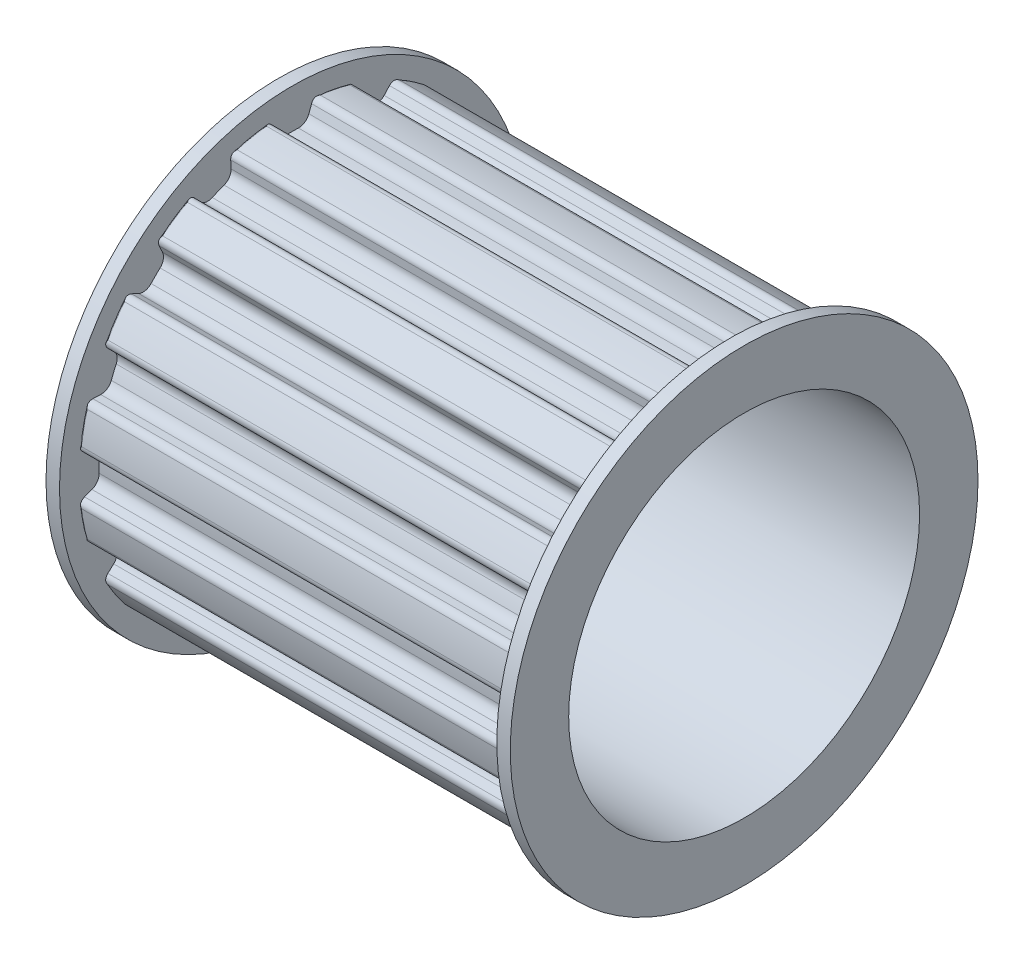
from build123d import *

# Parameters (mm, degrees)
CHAMFER_1_SIZE           = 1
FILLET_1_R               = 2
FILLET_2_R               = 2.5
CUT_EXTRUDE_3_DEPTH      = 123
PATTERN_CIRCULAR_3_COUNT = 16
EXTRUDE_START            = -123.002
SKETCH_7_R               = 25.3232
EXTRUDE_2_DEPTH          = 123.002
SKETCH_8_W               = 100
SKETCH_8_H               = 74.934258
CUT_EXTRUDE_4_DEPTH      = 40
SKETCH_9_R               = 34.654
EXTRUDE_3_DEPTH          = 2
SKETCH_10_R              = 34.454
EXTRUDE_4_DEPTH          = 2
SKETCH_11_R              = 21.5
CUT_EXTRUDE_5_DEPTH      = 10
SKETCH_12_R              = 26
CUT_EXTRUDE_6_DEPTH      = 40
SKETCH_13_R              = 2.5
CUT_EXTRUDE_7_DEPTH      = 60
SKETCH_17_R              = 11
SKETCH_17_R_2            = 2.5
CUT_EXTRUDE_9_DEPTH      = 1.5
SKETCH_15_R              = 1.5
CUT_EXTRUDE_8_DEPTH      = 30


with BuildPart() as part:
    # 草图1 → 旋转1 (revolve)
    with BuildSketch(Plane.XY):
        with BuildLine():
            Line((0, 6.3308), (0, 12.6616))
            Line((0, 12.6616), (44, 14.421131))
            Line((44, 14.421131), (44, 23.563669))
            Line((44, 23.563669), (0, 25.3232))
            Line((0, 25.3232), (0, 31.454))
            ThreePointArc((0, 31.454), (0.058579, 31.595421), (0.2, 31.654))
            Line((0.2, 31.654), (122.8, 31.654))
            ThreePointArc((122.8, 31.654), (122.941421, 31.595421), (123, 31.454))
            Line((123, 31.454), (123, 25.3232))
            Line((123, 25.3232), (79, 23.563669))
            Line((79, 23.563669), (79, 14.421131))
            Line((79, 14.421131), (123, 12.6616))
            Line((123, 12.6616), (123, 6.3308))
            Line((123, 6.3308), (0, 6.3308))
        make_face()
    revolve(axis=Axis((0, 0, 0), (1, 0, 0)))

    # 倒角1
    chamfer_1_edges = [part.edges().sort_by_distance(p)[0] for p in [
        (0, -6.3308, 0),
        (123, -6.3308, 0),
    ]]
    chamfer(chamfer_1_edges, length=CHAMFER_1_SIZE)

    # 圆角1
    fillet_1_edges = [part.edges().sort_by_distance(p)[0] for p in [
        (79, -14.421131, 0),
        (79, -23.563669, 0),
        (44, -23.563669, 0),
        (44, -14.421131, 0),
    ]]
    fillet(fillet_1_edges, radius=FILLET_1_R)

    # 圆角2
    fillet_2_edges = [part.edges().sort_by_distance(p)[0] for p in [
        (0, -12.6616, 0),
        (123, -12.6616, 0),
    ]]
    fillet(fillet_2_edges, radius=FILLET_2_R)

    # 草图6 → 切除-拉伸3 (cut)
    with BuildSketch(Plane(origin=(0, 0, 0), x_dir=(0, 0, -1), z_dir=(1, 0, 0))):
        with BuildLine():
            Line((-2.899999, 30.738893), (-2.500151, 29.64032))
            ThreePointArc((-2.500151, 29.64032), (-1.892614, 28.861944), (-0.943848, 28.588424))
            ThreePointArc((-0.943848, 28.588424), (0, 28.604), (0.943848, 28.588424))
            ThreePointArc((0.943848, 28.588424), (1.892614, 28.861944), (2.500151, 29.64032))
            Line((2.500151, 29.64032), (2.899999, 30.738893))
            ThreePointArc((2.899999, 30.738893), (3.327328, 31.26082), (3.986959, 31.401909))
            ThreePointArc((3.986959, 31.401909), (4.49238, 31.333596), (4.996634, 31.257149))
            Line((4.996634, 31.257149), (17.485538, 65.570129))
            ThreePointArc((17.485538, 65.570129), (0, 67.86152), (-17.485538, 65.570129))
            Line((-17.485538, 65.570129), (-4.996634, 31.257149))
            ThreePointArc((-4.996634, 31.257149), (-4.49238, 31.333596), (-3.986959, 31.401909))
            ThreePointArc((-3.986959, 31.401909), (-3.327328, 31.26082), (-2.899999, 30.738893))
        make_face()
    cut_extrude_3 = extrude(amount=CUT_EXTRUDE_3_DEPTH, mode=Mode.SUBTRACT)

    # 阵列(圆周)3: 切除-拉伸3 ×16 about axis
    pattern_circular_3_axis = Axis((0, 0, 0), (1, 0, 0))
    for i in range(1, PATTERN_CIRCULAR_3_COUNT):
        add(cut_extrude_3.rotate(pattern_circular_3_axis, i * 360 / PATTERN_CIRCULAR_3_COUNT), mode=Mode.SUBTRACT)

    # 草图7 → 凸台-拉伸2 (add)
    with BuildSketch(Plane.ZY.offset(EXTRUDE_START)):
        Circle(SKETCH_7_R)
    extrude(amount=EXTRUDE_2_DEPTH)

    # 草图8 → 切除-拉伸4 (cut, symmetric)
    with BuildSketch(Plane(origin=(0, 0, 0), x_dir=(1, 0, 0), z_dir=(0, 1, 0))):
        with Locations((115, -0.06522)):
            Rectangle(SKETCH_8_W, SKETCH_8_H)
    extrude(amount=CUT_EXTRUDE_4_DEPTH, both=True, mode=Mode.SUBTRACT)

    # 草图9 → 凸台-拉伸3 (add)
    with BuildSketch(Plane(origin=(65, 0, 0), x_dir=(0, 0, -1), z_dir=(1, 0, 0))):
        Circle(SKETCH_9_R)
    extrude(amount=EXTRUDE_3_DEPTH)

    # 草图10 → 凸台-拉伸4 (add)
    with BuildSketch(Plane.ZY):
        Circle(SKETCH_10_R)
    extrude(amount=EXTRUDE_4_DEPTH)

    # 草图11 → 切除-拉伸5 (cut)
    with BuildSketch(Plane.ZY.offset(2)):
        Circle(SKETCH_11_R)
    extrude(amount=-CUT_EXTRUDE_5_DEPTH, mode=Mode.SUBTRACT)

    # 草图12 → 切除-拉伸6 (cut)
    with BuildSketch(Plane(origin=(67, 0, 0), x_dir=(0, 0, -1), z_dir=(1, 0, 0))):
        Circle(SKETCH_12_R)
    extrude(amount=-CUT_EXTRUDE_6_DEPTH, mode=Mode.SUBTRACT)

    # 草图13 → 切除-拉伸7 (cut, through all)
    with BuildSketch(Plane.ZY.offset(-8)):
        Circle(SKETCH_13_R)
    extrude(amount=-CUT_EXTRUDE_7_DEPTH, mode=Mode.SUBTRACT)

    # 草图17 → 切除-拉伸9 (cut)
    with BuildSketch(Plane(origin=(8, 0, 0), x_dir=(0, 0, -1), z_dir=(1, 0, 0))):
        Circle(SKETCH_17_R)
        Circle(SKETCH_17_R_2, mode=Mode.SUBTRACT)
    extrude(amount=CUT_EXTRUDE_9_DEPTH, mode=Mode.SUBTRACT)

    # 草图15 → 切除-拉伸8 (cut, through all)
    with BuildSketch(Plane(origin=(27, 0, 0), x_dir=(0, 0, -1), z_dir=(1, 0, 0))):
        with Locations((0, 6)):
            Circle(SKETCH_15_R)
        with Locations((6, 0)):
            Circle(SKETCH_15_R)
        with Locations((0, -6)):
            Circle(SKETCH_15_R)
        with Locations((-6, 0)):
            Circle(SKETCH_15_R)
    extrude(amount=-CUT_EXTRUDE_8_DEPTH, mode=Mode.SUBTRACT)


solid = part.part
